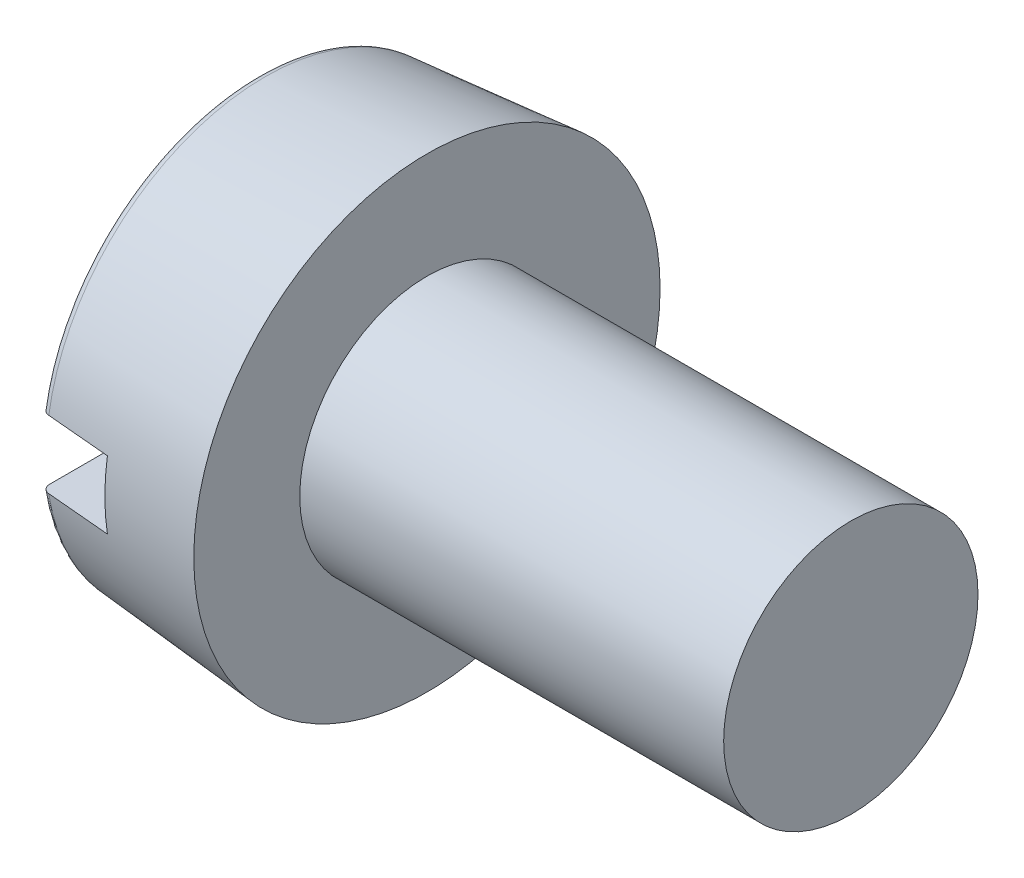
from build123d import *

# Parameters (mm, degrees)
FILLET2_R  = 0.1
SKETCH2_W  = 5.5
SKETCH2_H  = 0.8
SLOT_DEPTH = 0.85


with BuildPart() as part:
    # BodySke → Base-Revolve (revolve)
    with BuildSketch(Plane.XY, mode=Mode.PRIVATE) as base_revolve_sk:
        Polygon((2, 1.5), (2, 2.75), (0, 2.575022673), (0, 0), (7, 0), (7, 1.5), align=None)
    revolve(base_revolve_sk.sketch.rotate(Axis((-25.4, 0, 0), (1, 0, 0)), 90), axis=Axis((-25.4, 0, 0), (1, 0, 0)))  # turned: the seam where the file's is

    # Fillet2
    fillet2_edges = [part.edges().sort_by_distance(p)[0] for p in [
        (0, 0, -2.575022673),
    ]]
    fillet(fillet2_edges, radius=FILLET2_R)

    # Sketch2 → Slot (cut)
    with BuildSketch(Plane(origin=(0, 0, 0), x_dir=(0, 0, -1), z_dir=(1, 0, 0))):
        Rectangle(SKETCH2_W, SKETCH2_H)
    extrude(amount=SLOT_DEPTH, mode=Mode.SUBTRACT)


solid = part.part
